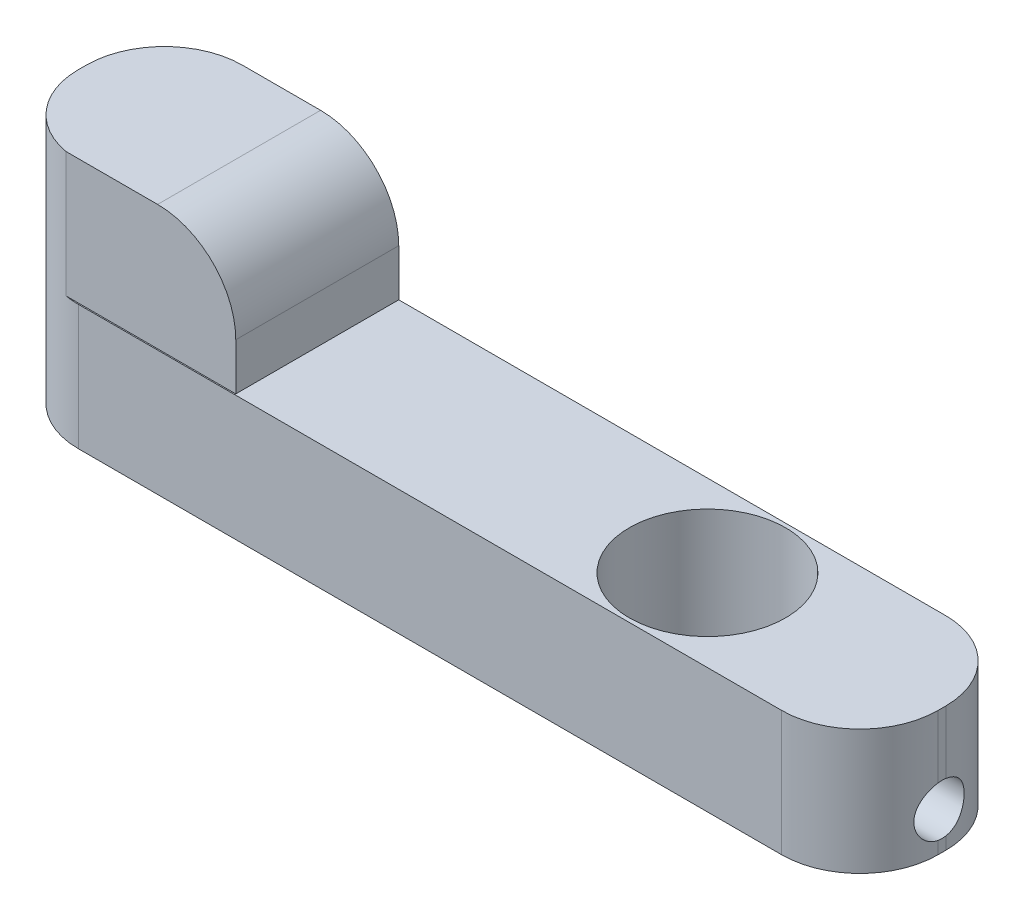
from build123d import *

# Parameters (mm, degrees)
SKETCH1_W           = 550
SKETCH1_H           = 105
SKETCH1_R           = 50
BOSS_EXTRUDE2_DEPTH = 80
FILLET4_R           = 50
FILLET5_R           = 50
SKETCH11_W          = 150
SKETCH11_H          = 104.268109322
BOSS_EXTRUDE3_DEPTH = 80
SKETCH12_R          = 5
BOSS_EXTRUDE4_DEPTH = 120
FILLET8_R           = 50
FILLET9_R           = 50
FILLET10_R          = 50
SKETCH13_R          = 16.1
CUT_EXTRUDE1_DEPTH  = 150


with BuildPart() as part:
    # Sketch1 → Boss-Extrude2 (new body)
    with BuildSketch(Plane(origin=(0, 0, 0), x_dir=(1, 0, 0), z_dir=(0, 1, 0))):
        Rectangle(SKETCH1_W, SKETCH1_H)
        with Locations((-220, 0)):
            Circle(SKETCH1_R, mode=Mode.SUBTRACT)
        with Locations((125, 0)):
            Circle(SKETCH1_R, mode=Mode.SUBTRACT)
    extrude(amount=BOSS_EXTRUDE2_DEPTH)

    # Fillet4
    fillet4_edges = [part.edges().sort_by_distance(p)[0] for p in [
        (275, 40, 52.5),
    ]]
    fillet(fillet4_edges, radius=FILLET4_R)

    # Fillet5
    fillet5_edges = [part.edges().sort_by_distance(p)[0] for p in [
        (275, 40, -52.5),
    ]]
    fillet(fillet5_edges, radius=FILLET5_R)

    # Sketch11 → Boss-Extrude3 (add)
    with BuildSketch(Plane(origin=(0, 80, 0), x_dir=(1, 0, 0), z_dir=(0, 1, 0))):
        with Locations((-200, 0.365945339)):
            Rectangle(SKETCH11_W, SKETCH11_H)
    extrude(amount=BOSS_EXTRUDE3_DEPTH)

    # Sketch12 → Boss-Extrude4 (add)
    with BuildSketch(Plane.XZ.offset(-80)):
        with Locations((-220, 0)):
            Circle(SKETCH12_R)
    extrude(amount=BOSS_EXTRUDE4_DEPTH)

    # Fillet8
    fillet8_edges = [part.edges().sort_by_distance(p)[0] for p in [
        (-275, 40, 52.5),
    ]]
    fillet(fillet8_edges, radius=FILLET8_R)

    # Fillet9
    fillet9_edges = [part.edges().sort_by_distance(p)[0] for p in [
        (-275, 80, -52.5),
    ]]
    fillet(fillet9_edges, radius=FILLET9_R)

    # Fillet10
    fillet10_edges = [part.edges().sort_by_distance(p)[0] for p in [
        (-125, 160, -0.365945339),
    ]]
    fillet(fillet10_edges, radius=FILLET10_R)

    # Sketch13 → Cut-Extrude1 (cut)
    with BuildSketch(Plane(origin=(275, 0, 0), x_dir=(0, 0, -1), z_dir=(1, 0, 0))):
        with Locations((0, 23.9)):
            Circle(SKETCH13_R)
    extrude(amount=-CUT_EXTRUDE1_DEPTH, mode=Mode.SUBTRACT)


solid = part.part
